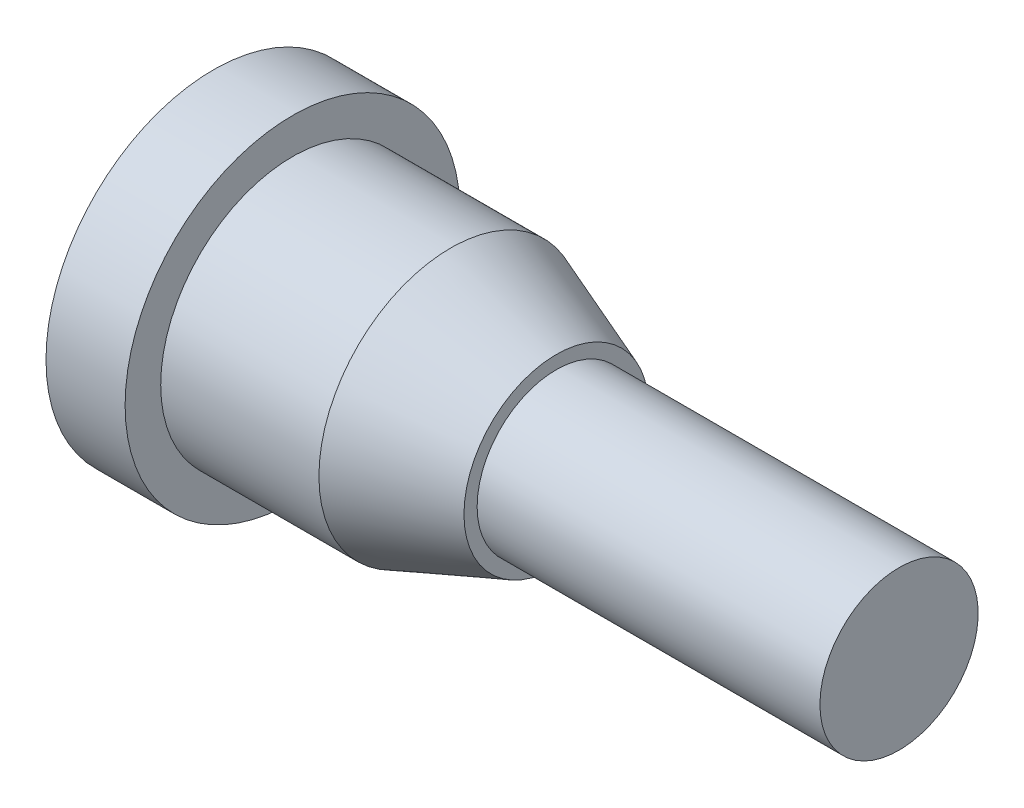
from build123d import *


with BuildPart() as part:
    # Sketch1 → Revolve1 (revolve)
    with BuildSketch(Plane.XY):
        Polygon((0, 0), (0, 6.35), (3, 6.35), (3, 5), (9, 5), (13, 3.5), (13, 3), (26, 3), (26, 0), align=None)
    revolve(axis=Axis((-5.032456996, 0, 0), (1, 0, 0)))


solid = part.part
